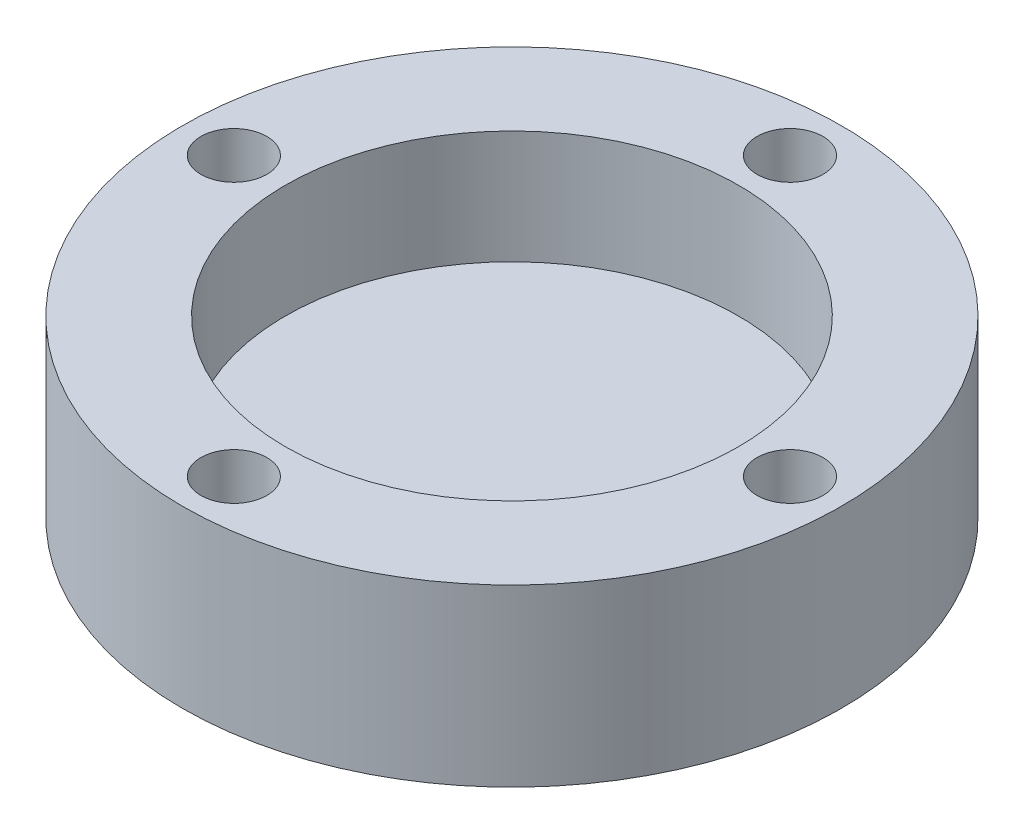
from build123d import *

# Parameters (mm, degrees)
ESQUISSE2_R                = 1.6
FIXINGHOLE_DEPTH           = 9.5
FIXINGHOLEREPETITION_COUNT = 4


with BuildPart() as part:
    # Esquisse1 → MainRevolution (revolve)
    with BuildSketch(Plane.XY):
        Polygon((11, 8.5), (11, 3), (0, 3), (0, 0), (16, 0), (16, 8.5), align=None)
    revolve(axis=Axis((0, 8.4, 0), (0, -1, 0)))

    # Esquisse2 → FixingHole (cut, through all)
    with BuildSketch(Plane(origin=(0, 8.5, 0), x_dir=(1, 0, 0), z_dir=(0, 1, 0))):
        with Locations((13.5, 0)):
            Circle(ESQUISSE2_R)
    fixinghole = extrude(amount=-FIXINGHOLE_DEPTH, mode=Mode.SUBTRACT)

    # FixingHoleRepetition: FixingHole ×4 about axis
    fixingholerepetition_axis = Axis((0, 0, 0), (0, 1, 0))
    for i in range(1, FIXINGHOLEREPETITION_COUNT):
        add(fixinghole.rotate(fixingholerepetition_axis, i * 360 / FIXINGHOLEREPETITION_COUNT), mode=Mode.SUBTRACT)


solid = part.part
